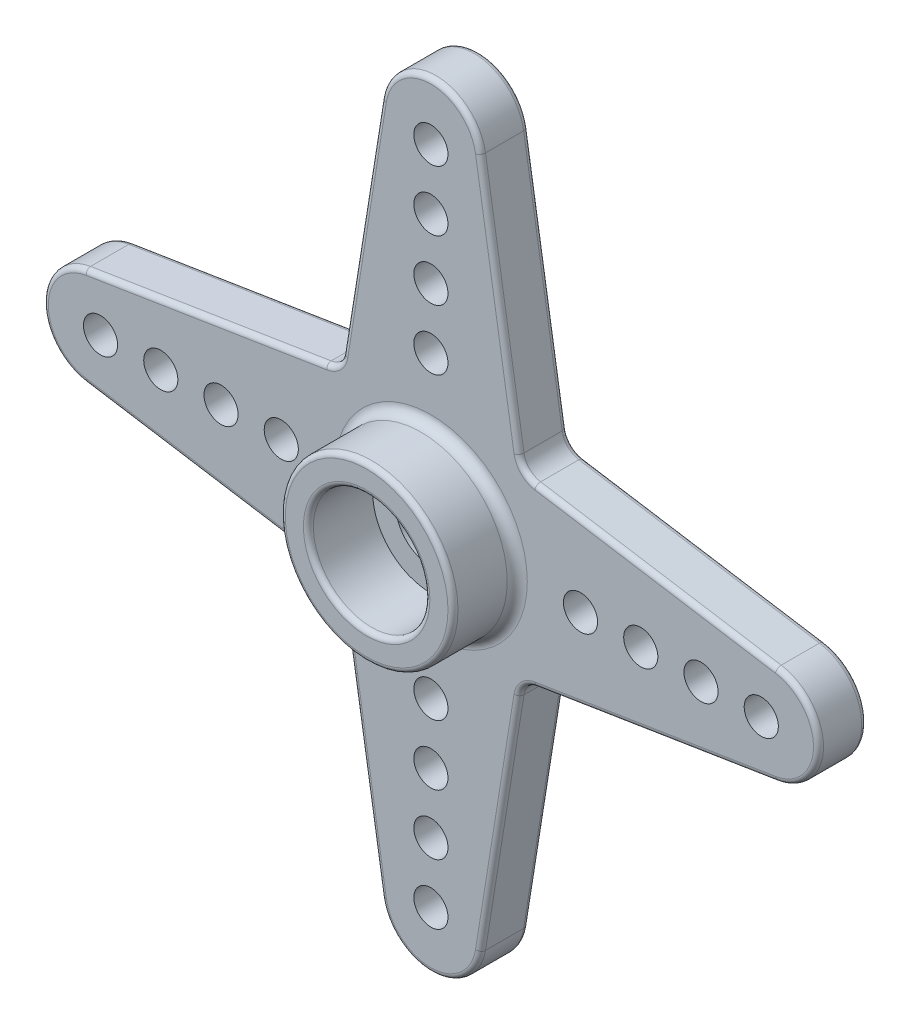
from build123d import *

# Parameters (mm, degrees)
SKETCH1_R                   = 1.75
BOSS_EXTRUDE1_DEPTH         = 2.4
SKETCH2_R                   = 4.3
SKETCH2_R_2                 = 2.9
BOSS_EXTRUDE2_DEPTH         = 3.2
SKETCH4_R                   = 3.6
SKETCH4_R_2                 = 3.3
BOSS_EXTRUDE3_DEPTH         = 0.2
CUT_EXTRUDE2_START          = -0.4
SKETCH5_R                   = 4
SKETCH5_R_2                 = 3.6
SKETCH5_R_3                 = 3.3
CUT_EXTRUDE2_DEPTH          = 0.4
SKETCH6_R                   = 0.85
CUT_EXTRUDE3_DEPTH          = 28.86287853
LPATTERN1_COUNT             = 4
LPATTERN1_PITCH             = 3
CIRPATTERN1_COUNT           = 4
CIRPATTERN1_COPY_1_SKETCH_R = 0.85
CIRPATTERN1_COPY_1_DEPTH    = 28.86287853
CIRPATTERN1_COPY_2_SKETCH_R = 0.85
CIRPATTERN1_COPY_2_DEPTH    = 28.86287853
CIRPATTERN1_COPY_3_SKETCH_R = 0.85
CIRPATTERN1_COPY_3_DEPTH    = 28.86287853
CIRPATTERN1_COPY_4_SKETCH_R = 0.85
CIRPATTERN1_COPY_4_DEPTH    = 28.86287853
CIRPATTERN1_COPY_5_SKETCH_R = 0.85
CIRPATTERN1_COPY_5_DEPTH    = 28.86287853
CIRPATTERN1_COPY_6_SKETCH_R = 0.85
CIRPATTERN1_COPY_6_DEPTH    = 28.86287853
CIRPATTERN1_COPY_7_SKETCH_R = 0.85
CIRPATTERN1_COPY_7_DEPTH    = 28.86287853
CIRPATTERN1_COPY_8_SKETCH_R = 0.85
CIRPATTERN1_COPY_8_DEPTH    = 28.86287853
CIRPATTERN1_COPY_9_SKETCH_R = 0.85
CIRPATTERN1_COPY_9_DEPTH    = 28.86287853
FILLET3_R                   = 1
FILLET1_R                   = 0.25
FILLET2_R                   = 0.5


with BuildPart() as part:
    # Sketch1 → Boss-Extrude1 (new body)
    with BuildSketch(Plane.XY):
        with BuildLine():
            Line((-4.5, 4.5), (-17.195014594, 2.468595445))
            ThreePointArc((-17.195014594, 2.468595445), (-19.3, 0), (-17.195014594, -2.468595445))
            Line((-17.195014594, -2.468595445), (-4.5, -4.5))
            Line((-4.5, -4.5), (-2.468595445, -17.195014594))
            ThreePointArc((-2.468595445, -17.195014594), (0, -19.3), (2.468595445, -17.195014594))
            Line((2.468595445, -17.195014594), (4.5, -4.5))
            Line((4.5, -4.5), (17.195014594, -2.468595445))
            ThreePointArc((17.195014594, -2.468595445), (19.3, 0), (17.195014594, 2.468595445))
            Line((17.195014594, 2.468595445), (4.5, 4.5))
            Line((4.5, 4.5), (2.468595445, 17.195014594))
            ThreePointArc((2.468595445, 17.195014594), (0, 19.3), (-2.468595445, 17.195014594))
            Line((-2.468595445, 17.195014594), (-4.5, 4.5))
        make_face()
        Circle(SKETCH1_R, mode=Mode.SUBTRACT)
    extrude(amount=BOSS_EXTRUDE1_DEPTH)

    # Sketch2 → Boss-Extrude2 (add)
    with BuildSketch(Plane.XY.offset(2.4)):
        Circle(SKETCH2_R)
        Circle(SKETCH2_R_2, mode=Mode.SUBTRACT)
    extrude(amount=BOSS_EXTRUDE2_DEPTH)

    # Sketch4 → Boss-Extrude3 (add)
    with BuildSketch(Plane(origin=(0, 0, 0), x_dir=(-1, 0, 0), z_dir=(0, 0, -1))):
        with Locations(Location((0, 0, 0), (0, 0, 180))):
            Circle(SKETCH4_R)
        Circle(SKETCH4_R_2, mode=Mode.SUBTRACT)
    extrude(amount=BOSS_EXTRUDE3_DEPTH)

    # Sketch5 → Cut-Extrude2 (cut)
    # profile 1 of 2: a face of its own
    with BuildSketch(Plane(origin=(0, 0, 0), x_dir=(-1, 0, 0), z_dir=(0, 0, -1)).offset(CUT_EXTRUDE2_START)):
        Circle(SKETCH5_R)
        Circle(SKETCH5_R_2, mode=Mode.SUBTRACT)
    # profile 2 of 2: a face of its own
    with BuildSketch(Plane(origin=(0, 0, 0), x_dir=(-1, 0, 0), z_dir=(0, 0, -1)).offset(CUT_EXTRUDE2_START)):
        Circle(SKETCH5_R_3)
    extrude(amount=CUT_EXTRUDE2_DEPTH, mode=Mode.SUBTRACT)

    # Sketch6 → Cut-Extrude3 (cut, through all)
    with BuildSketch(Plane(origin=(0, 0, 0), x_dir=(-1, 0, 0), z_dir=(0, 0, -1))):
        with Locations((7.45, 0)):
            Circle(SKETCH6_R)
    cut_extrude3 = extrude(amount=-CUT_EXTRUDE3_DEPTH, mode=Mode.SUBTRACT)

    # LPattern1: Cut-Extrude3 ×4
    with Locations(*[(-i * LPATTERN1_PITCH, 0, 0) for i in range(1, LPATTERN1_COUNT)]):
        add(cut_extrude3, mode=Mode.SUBTRACT)

    # CirPattern1: Cut-Extrude3 ×4 about axis
    cirpattern1_axis = Axis((0, 0, 0), (0, 0, 1))
    for i in range(1, CIRPATTERN1_COUNT):
        add(cut_extrude3.rotate(cirpattern1_axis, i * 360 / CIRPATTERN1_COUNT), mode=Mode.SUBTRACT)

    # CirPattern1 copy 1 sketch → CirPattern1 copy 1 (cut, through all)
    with BuildSketch(Plane(origin=(0, -3, 0), x_dir=(0, -1, 0), z_dir=(0, 0, -1))):
        with Locations((7.45, 0)):
            Circle(CIRPATTERN1_COPY_1_SKETCH_R)
    extrude(amount=-CIRPATTERN1_COPY_1_DEPTH, mode=Mode.SUBTRACT)

    # CirPattern1 copy 2 sketch → CirPattern1 copy 2 (cut, through all)
    with BuildSketch(Plane(origin=(3, 0, 0), x_dir=(1, 0, 0), z_dir=(0, 0, -1))):
        with Locations((7.45, 0)):
            Circle(CIRPATTERN1_COPY_2_SKETCH_R)
    extrude(amount=-CIRPATTERN1_COPY_2_DEPTH, mode=Mode.SUBTRACT)

    # CirPattern1 copy 3 sketch → CirPattern1 copy 3 (cut, through all)
    with BuildSketch(Plane(origin=(0, 3, 0), x_dir=(0, 1, 0), z_dir=(0, 0, -1))):
        with Locations((7.45, 0)):
            Circle(CIRPATTERN1_COPY_3_SKETCH_R)
    extrude(amount=-CIRPATTERN1_COPY_3_DEPTH, mode=Mode.SUBTRACT)

    # CirPattern1 copy 4 sketch → CirPattern1 copy 4 (cut, through all)
    with BuildSketch(Plane(origin=(0, -6, 0), x_dir=(0, -1, 0), z_dir=(0, 0, -1))):
        with Locations((7.45, 0)):
            Circle(CIRPATTERN1_COPY_4_SKETCH_R)
    extrude(amount=-CIRPATTERN1_COPY_4_DEPTH, mode=Mode.SUBTRACT)

    # CirPattern1 copy 5 sketch → CirPattern1 copy 5 (cut, through all)
    with BuildSketch(Plane(origin=(6, 0, 0), x_dir=(1, 0, 0), z_dir=(0, 0, -1))):
        with Locations((7.45, 0)):
            Circle(CIRPATTERN1_COPY_5_SKETCH_R)
    extrude(amount=-CIRPATTERN1_COPY_5_DEPTH, mode=Mode.SUBTRACT)

    # CirPattern1 copy 6 sketch → CirPattern1 copy 6 (cut, through all)
    with BuildSketch(Plane(origin=(0, 6, 0), x_dir=(0, 1, 0), z_dir=(0, 0, -1))):
        with Locations((7.45, 0)):
            Circle(CIRPATTERN1_COPY_6_SKETCH_R)
    extrude(amount=-CIRPATTERN1_COPY_6_DEPTH, mode=Mode.SUBTRACT)

    # CirPattern1 copy 7 sketch → CirPattern1 copy 7 (cut, through all)
    with BuildSketch(Plane(origin=(0, -9, 0), x_dir=(0, -1, 0), z_dir=(0, 0, -1))):
        with Locations((7.45, 0)):
            Circle(CIRPATTERN1_COPY_7_SKETCH_R)
    extrude(amount=-CIRPATTERN1_COPY_7_DEPTH, mode=Mode.SUBTRACT)

    # CirPattern1 copy 8 sketch → CirPattern1 copy 8 (cut, through all)
    with BuildSketch(Plane(origin=(9, 0, 0), x_dir=(1, 0, 0), z_dir=(0, 0, -1))):
        with Locations((7.45, 0)):
            Circle(CIRPATTERN1_COPY_8_SKETCH_R)
    extrude(amount=-CIRPATTERN1_COPY_8_DEPTH, mode=Mode.SUBTRACT)

    # CirPattern1 copy 9 sketch → CirPattern1 copy 9 (cut, through all)
    with BuildSketch(Plane(origin=(0, 9, 0), x_dir=(0, 1, 0), z_dir=(0, 0, -1))):
        with Locations((7.45, 0)):
            Circle(CIRPATTERN1_COPY_9_SKETCH_R)
    extrude(amount=-CIRPATTERN1_COPY_9_DEPTH, mode=Mode.SUBTRACT)

    # Fillet3
    fillet3_edges = [part.edges().sort_by_distance(p)[0] for p in [
        (4.5, 4.5, 1.2),
        (4.5, -4.5, 1.2),
        (-4.5, -4.5, 1.2),
        (-4.5, 4.5, 1.2),
    ]]
    fillet(fillet3_edges, radius=FILLET3_R)

    # Fillet1
    fillet1_edges = [part.edges().sort_by_distance(p)[0] for p in [
        (11.205016327, 3.427090583, 0),
        (19.3, 0, 0),
        (3.427090583, -11.205016327, 0),
        (0, -19.3, 0),
        (-19.3, 0, 2.4),
        (-11.205016327, -3.427090583, 0),
        (-19.3, 0, 0),
        (-3.427090583, -11.205016327, 0),
        (-3.427090583, 11.205016327, 0),
        (-3.427090583, -11.205016327, 2.4),
        (11.205016327, -3.427090583, 0),
        (11.205016327, -3.427090583, 2.4),
        (0, 19.3, 0),
        (3.427090583, 11.205016327, 0),
        (3.427090583, 11.205016327, 2.4),
        (-11.205016327, 3.427090583, 0),
        (-11.205016327, 3.427090583, 2.4),
        (-4.665917117, -4.665917117, 0),
        (-4.665917117, -4.665917117, 2.4),
        (4.665917117, -4.665917117, 0),
        (4.665917117, -4.665917117, 2.4),
        (4.665917117, 4.665917117, 0),
        (4.665917117, 4.665917117, 2.4),
        (-4.665917117, 4.665917117, 0),
        (-11.205016327, -3.427090583, 2.4),
        (-4.665917117, 4.665917117, 2.4),
        (0, -19.3, 2.4),
        (3.427090583, -11.205016327, 2.4),
        (19.3, 0, 2.4),
        (11.205016327, 3.427090583, 2.4),
        (-4.3, 0, 5.6),
        (0, 19.3, 2.4),
        (-2.9, 0, 5.6),
        (-3.427090583, 11.205016327, 2.4),
    ]]
    fillet(fillet1_edges, radius=FILLET1_R)

    # Fillet2
    fillet2_edges = [part.edges().sort_by_distance(p)[0] for p in [
        (-4.3, 0, 2.4),
    ]]
    fillet(fillet2_edges, radius=FILLET2_R)


solid = part.part
